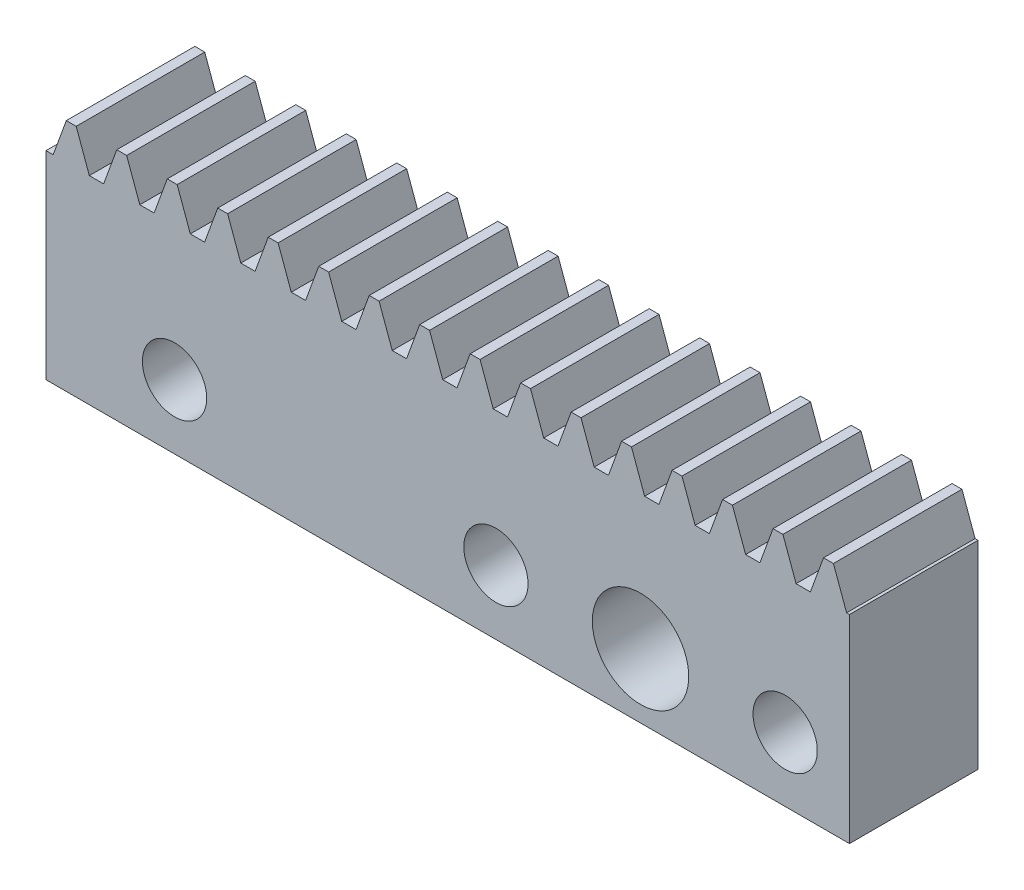
from build123d import *

# Parameters (mm, degrees)
BLANKSKE_W         = 25
BLANKSKE_H         = 7.3
BLANK_DEPTH        = 4
TOOTHCUTSIM_DEPTH  = 27.349383294
TEETHCUTS_COUNT    = 17
TEETHCUTS_PITCH    = 1.570796325
CUT_EXTRUDE1_DEPTH = 27.349383294


with BuildPart() as part:
    # BlankSke → Blank (new body)
    with BuildSketch(Plane.XY):
        with Locations((12.5, 3.65)):
            Rectangle(BLANKSKE_W, BLANKSKE_H)
    extrude(amount=-BLANK_DEPTH)

    # TooCutSkeSim → ToothCutSim (cut, through all)
    with BuildSketch(Plane.XY):
        Polygon((0.222217685, 6.175), (-0.222217685, 6.175), (-0.640929042, 7.3254), (0.640929042, 7.3254), align=None)
    toothcutsim = extrude(amount=-TOOTHCUTSIM_DEPTH, mode=Mode.SUBTRACT)

    # TeethCuts: ToothCutSim ×17
    with Locations(*[(i * TEETHCUTS_PITCH, 0, 0) for i in range(1, TEETHCUTS_COUNT)]):
        add(toothcutsim, mode=Mode.SUBTRACT)

    # Sketch1 → Cut-Extrude1 (cut, through all)
    with BuildSketch(Plane(origin=(0, 0, -4), x_dir=(-1, 0, 0), z_dir=(0, 0, -1))):
        with BuildLine():
            Line((-23, 1), (-23, 2))
            Line((-23, 2), (-24, 2))
            ThreePointArc((-24, 2), (-23.707106781, 1.292893219), (-23, 1))
        make_face()
        with BuildLine():
            Line((-24, 2), (-23, 2))
            Line((-23, 2), (-23, 3))
            ThreePointArc((-23, 3), (-23.707106781, 2.707106781), (-24, 2))
        make_face()
        with BuildLine():
            Line((-23, 3), (-23, 2))
            Line((-23, 2), (-23, 1))
            ThreePointArc((-23, 1), (-22.292893219, 1.292893219), (-22, 2))
            ThreePointArc((-22, 2), (-22.292893219, 2.707106781), (-23, 3))
        make_face()
        with BuildLine():
            ThreePointArc((-17, 2), (-18.5, 3.5), (-20, 2))
            Line((-20, 2), (-17, 2))
        make_face()
        with BuildLine():
            Line((-17, 2), (-20, 2))
            ThreePointArc((-20, 2), (-18.5, 0.5), (-17, 2))
        make_face()
        with BuildLine():
            ThreePointArc((-13, 2), (-14, 3), (-15, 2))
            Line((-15, 2), (-13, 2))
        make_face()
        with BuildLine():
            Line((-13, 2), (-15, 2))
            ThreePointArc((-15, 2), (-14, 1), (-13, 2))
        make_face()
        with BuildLine():
            ThreePointArc((-3, 2), (-4, 3), (-5, 2))
            Line((-5, 2), (-3, 2))
        make_face()
        with BuildLine():
            Line((-3, 2), (-5, 2))
            ThreePointArc((-5, 2), (-4, 1), (-3, 2))
        make_face()
    extrude(amount=-CUT_EXTRUDE1_DEPTH, mode=Mode.SUBTRACT)


solid = part.part
